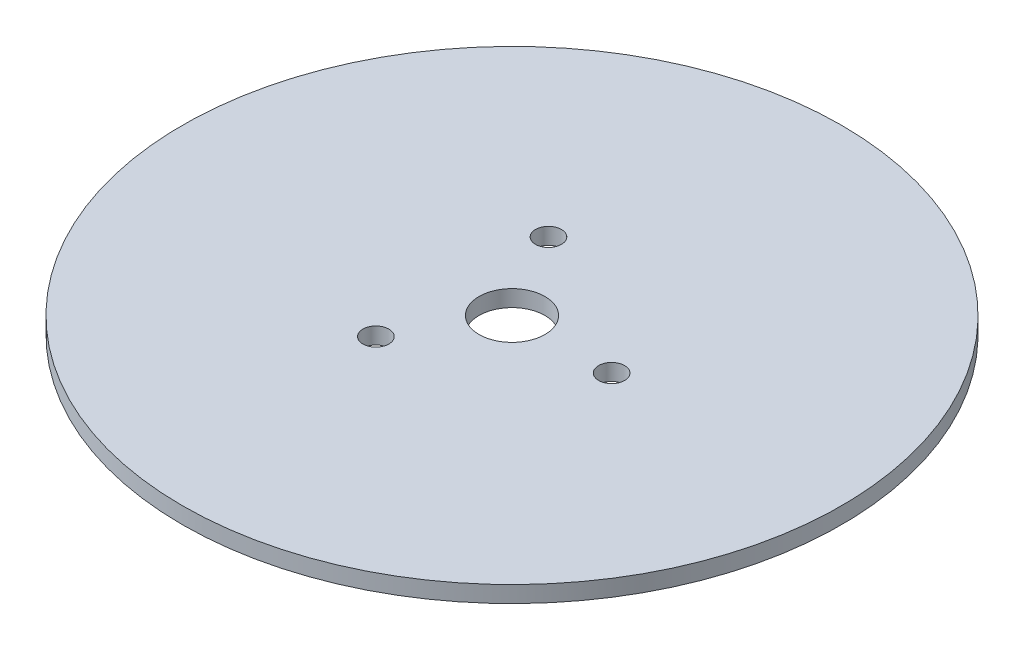
from build123d import *

# Parameters (mm, degrees)
SKETCH1_R           = 63.5
SKETCH1_R_2         = 2.5
SKETCH1_R_3         = 6.35
BOSS_EXTRUDE1_DEPTH = 3.175


with BuildPart() as part:
    # Sketch1 → Boss-Extrude1 (new body)
    with BuildSketch(Plane(origin=(0, 0, 0), x_dir=(1, 0, 0), z_dir=(0, 1, 0))):
        Circle(SKETCH1_R)
        with Locations((19.2, 0)):
            Circle(SKETCH1_R_2, mode=Mode.SUBTRACT)
        with Locations((-9.6, 16.627687753)):
            Circle(SKETCH1_R_2, mode=Mode.SUBTRACT)
        with Locations((-9.6, -16.627687753)):
            Circle(SKETCH1_R_2, mode=Mode.SUBTRACT)
        Circle(SKETCH1_R_3, mode=Mode.SUBTRACT)
    extrude(amount=BOSS_EXTRUDE1_DEPTH)


solid = part.part
